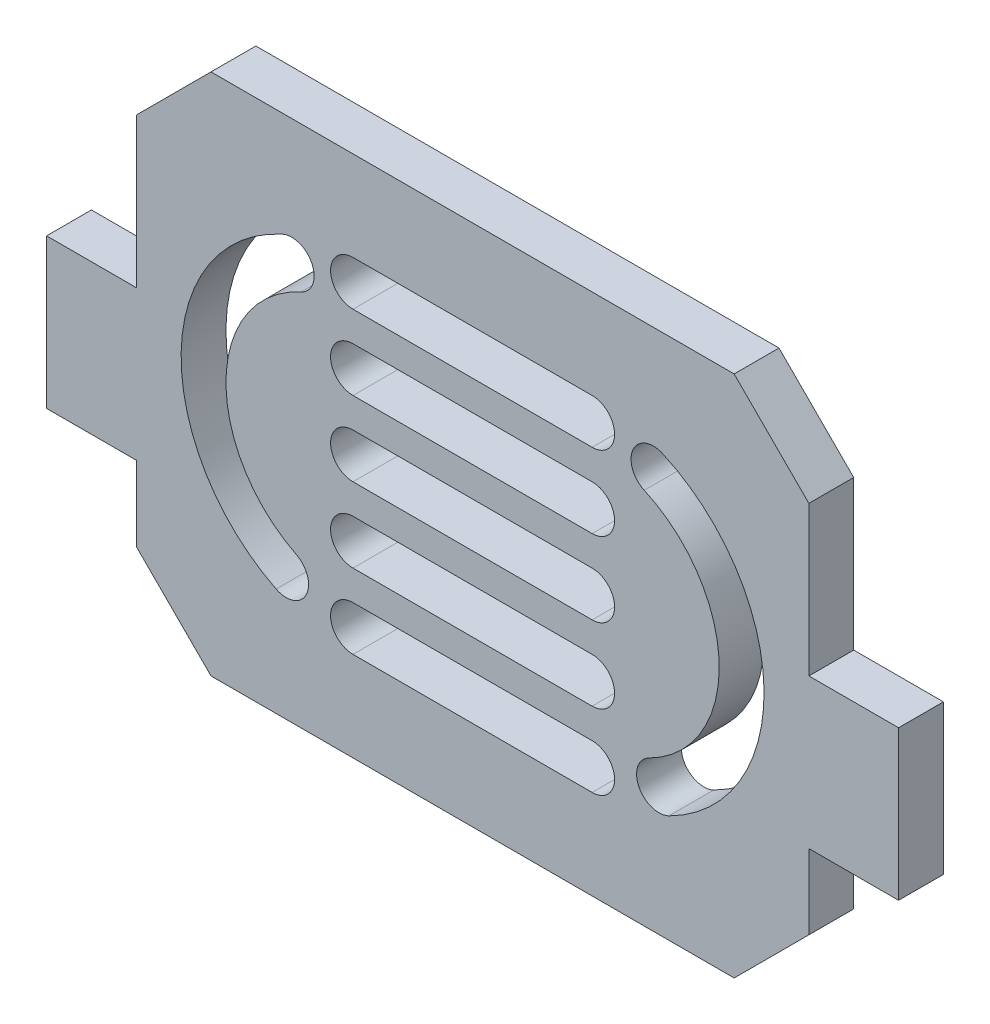
from build123d import *

# Parameters (mm, degrees)
BOSS_EXTRUDE1_DEPTH = 3
CHAMFER1_SIZE       = 5
CUT_EXTRUDE1_DEPTH  = 5


with BuildPart() as part:
    # Sketch1 → Boss-Extrude1 (new body)
    with BuildSketch(Plane.XY):
        Polygon((22.5, -7.5), (22.5, -17.5), (-22.5, -17.5), (-22.5, -7.5), (-28.5, -7.5), (-28.5, 2.5), (-22.5, 2.5), (-22.5, 17.5), (22.5, 17.5), (22.5, 2.5), (28.5, 2.5), (28.5, -7.5), align=None)
    extrude(amount=BOSS_EXTRUDE1_DEPTH)

    # Chamfer1
    chamfer1_edges = [part.edges().sort_by_distance(p)[0] for p in [
        (-22.5, -17.5, 1.5),
        (-22.5, 17.5, 1.5),
        (22.5, 17.5, 1.5),
        (22.5, -17.5, 1.5),
    ]]
    chamfer(chamfer1_edges, length=CHAMFER1_SIZE)

    # Sketch2 → Cut-Extrude1 (cut)
    with BuildSketch(Plane.XY.offset(3)):
        with BuildLine():
            Line((-8, 1.5), (8, 1.5))
            ThreePointArc((8, 1.5), (9.5, 0), (8, -1.5))
            Line((8, -1.5), (-8, -1.5))
            ThreePointArc((-8, -1.5), (-9.5, 0), (-8, 1.5))
        make_face()
        with BuildLine():
            Line((-8, 6.5), (8, 6.5))
            ThreePointArc((8, 6.5), (9.5, 5), (8, 3.5))
            Line((8, 3.5), (-8, 3.5))
            ThreePointArc((-8, 3.5), (-9.5, 5), (-8, 6.5))
        make_face()
        with BuildLine():
            Line((-8, 11.5), (8, 11.5))
            ThreePointArc((8, 11.5), (9.5, 10), (8, 8.5))
            Line((8, 8.5), (-8, 8.5))
            ThreePointArc((-8, 8.5), (-9.5, 10), (-8, 11.5))
        make_face()
        with BuildLine():
            Line((-8, -3.5), (8, -3.5))
            ThreePointArc((8, -3.5), (9.5, -5), (8, -6.5))
            Line((8, -6.5), (-8, -6.5))
            ThreePointArc((-8, -6.5), (-9.5, -5), (-8, -3.5))
        make_face()
        with BuildLine():
            Line((-8, -8.5), (8, -8.5))
            ThreePointArc((8, -8.5), (9.5, -10), (8, -11.5))
            Line((8, -11.5), (-8, -11.5))
            ThreePointArc((-8, -11.5), (-9.5, -10), (-8, -8.5))
        make_face()
        with BuildLine():
            ThreePointArc((-12.715686471, 10.488674897), (-19.497563389, 0.236719508), (-13.143402946, -10.285689385))
            ThreePointArc((-13.143402946, -10.285689385), (-11.130912642, -9.614956372), (-11.801645656, -7.602466067))
            ThreePointArc((-11.801645656, -7.602466067), (-16.498199026, 0.174966593), (-11.485507392, 7.752498837))
            ThreePointArc((-11.485507392, 7.752498837), (-10.732508901, 9.735676407), (-12.715686471, 10.488674897))
        make_face()
        with BuildLine():
            ThreePointArc((12.715686471, 10.488674897), (19.497563389, 0.236719508), (13.143402946, -10.285689385))
            ThreePointArc((13.143402946, -10.285689385), (11.130912642, -9.614956372), (11.801645656, -7.602466067))
            ThreePointArc((11.801645656, -7.602466067), (16.498199026, 0.174966593), (11.485507392, 7.752498837))
            ThreePointArc((11.485507392, 7.752498837), (10.732508901, 9.735676407), (12.715686471, 10.488674897))
        make_face()
    extrude(amount=-CUT_EXTRUDE1_DEPTH, mode=Mode.SUBTRACT)


solid = part.part
